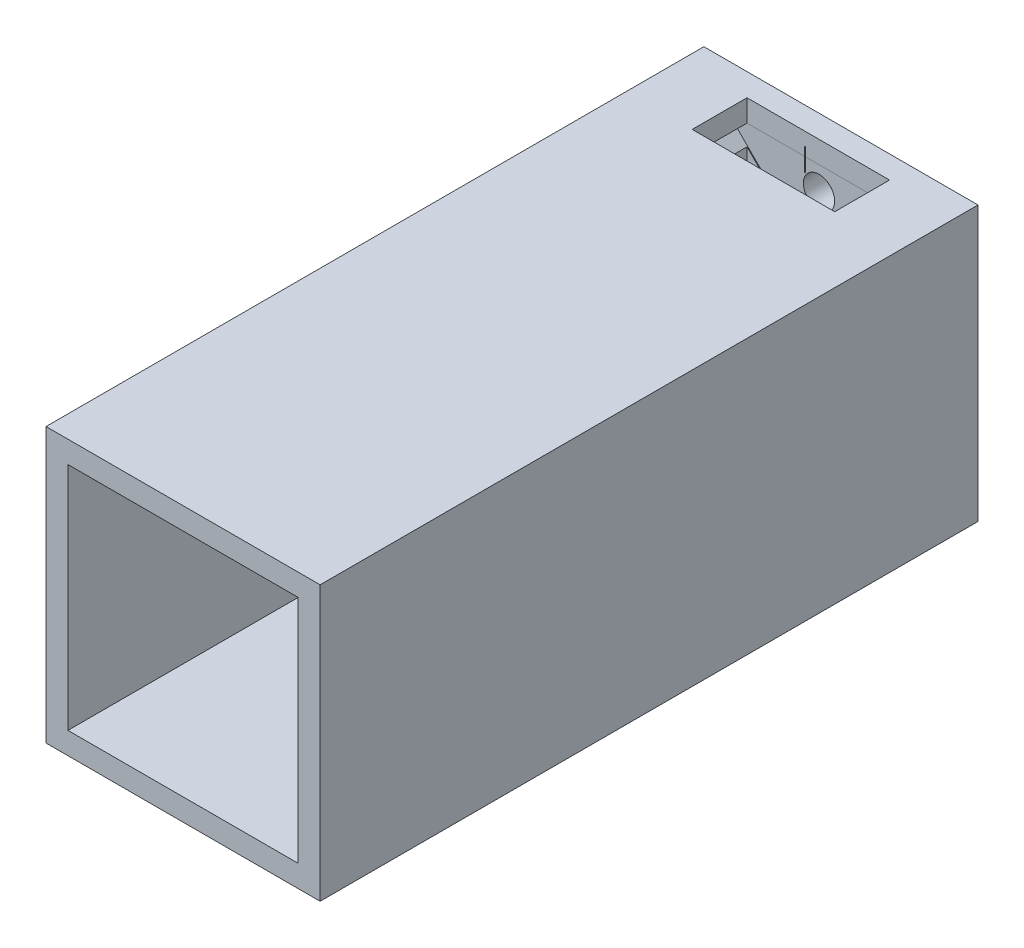
from build123d import *

# Parameters (mm, degrees)
SKETCH1_W           = 25
SKETCH1_H           = 25
BOSS_EXTRUDE1_DEPTH = 60
SHELL1_T            = -2
SKETCH2_R           = 2.5
SKETCH2_R_2         = 1.425
CUT_EXTRUDE4_DEPTH  = 2
BOSS_EXTRUDE3_DEPTH = 30
SKETCH5_W           = 13
SKETCH5_H           = 5
SKETCH5_R           = 0.024622166
CUT_EXTRUDE6_DEPTH  = 10


with BuildPart() as part:
    # Sketch1 → Boss-Extrude1 (new body)
    with BuildSketch(Plane.XY):
        Rectangle(SKETCH1_W, SKETCH1_H)
    extrude(amount=BOSS_EXTRUDE1_DEPTH)

    # Shell1
    shell1_openings = [part.faces().sort_by_distance(p)[0] for p in [
        (0, 0, 60),
    ]]
    offset(amount=SHELL1_T, openings=shell1_openings, kind=Kind.INTERSECTION)

    # Sketch2 → Cut-Extrude4 (cut)
    with BuildSketch(Plane.XY):
        Circle(SKETCH2_R)
        with Locations((8.25, 0)):
            Circle(SKETCH2_R_2)
        with Locations((0, -8.25)):
            Circle(SKETCH2_R_2)
        with Locations((-8.25, 0)):
            Circle(SKETCH2_R_2)
        with Locations((0, 8.25)):
            Circle(SKETCH2_R_2)
    extrude(amount=CUT_EXTRUDE4_DEPTH, mode=Mode.SUBTRACT)

    # Sketch4 → Boss-Extrude3 (add)
    with BuildSketch(Plane.XY.offset(2)):
        with BuildLine():
            Line((-8.871320344, 6.75), (-6.792832126, 4.671511782))
            ThreePointArc((-6.792832126, 4.671511782), (-6.28187766, 5.363494358), (-5.703280287, 6))
            Line((-5.703280287, 6), (-3.878679656, 6))
            Line((-3.878679656, 6), (-4.628679656, 6.75))
            Line((-4.628679656, 6.75), (-8.871320344, 6.75))
        make_face()
        Polygon((-10.5, 8.378679656), (-8.871320344, 6.75), (-4.628679656, 6.75), (-8.378679656, 10.5), (-10.5, 10.5), align=None)
        Polygon((-3.878679656, 6), (0, 6), (3.878679656, 6), (4.628679656, 6.75), (-4.628679656, 6.75), align=None)
        Polygon((8.378679656, 10.5), (4.628679656, 6.75), (8.871320344, 6.75), (10.5, 8.378679656), (10.5, 10.5), align=None)
        with BuildLine():
            Line((4.628679656, 6.75), (3.878679656, 6))
            Line((3.878679656, 6), (4.296719713, 6))
            ThreePointArc((4.296719713, 6), (5.489948643, 5.313054416), (6.513606116, 4.392285772))
            Line((6.513606116, 4.392285772), (8.871320344, 6.75))
            Line((8.871320344, 6.75), (4.628679656, 6.75))
        make_face()
        with BuildLine():
            ThreePointArc((-5.703280287, -6), (-6.28187766, -5.363494358), (-6.792832126, -4.671511782))
            Line((-6.792832126, -4.671511782), (-8.871320344, -6.75))
            Line((-8.871320344, -6.75), (-4.628679656, -6.75))
            Line((-4.628679656, -6.75), (-3.878679656, -6))
            Line((-3.878679656, -6), (-5.703280287, -6))
        make_face()
        with BuildLine():
            Line((4.296719713, -6), (3.878679656, -6))
            Line((3.878679656, -6), (4.628679656, -6.75))
            Line((4.628679656, -6.75), (8.871320344, -6.75))
            Line((8.871320344, -6.75), (6.513606116, -4.392285772))
            ThreePointArc((6.513606116, -4.392285772), (5.489948643, -5.313054416), (4.296719713, -6))
        make_face()
        Polygon((-4.628679656, -6.75), (-8.871320344, -6.75), (-10.5, -8.378679656), (-10.5, -10.5), (-8.378679656, -10.5), align=None)
        Polygon((8.871320344, -6.75), (4.628679656, -6.75), (8.378679656, -10.5), (10.5, -10.5), (10.5, -8.378679656), align=None)
        with BuildLine():
            Line((8.871320344, 6.75), (6.513606116, 4.392285772))
            ThreePointArc((6.513606116, 4.392285772), (7.473760778, 3.000900651), (8.046659593, 1.410417555))
            ThreePointArc((8.046659593, 1.410417555), (8.886964121, 1.274716325), (9.5, 0.684196609))
            Line((9.5, 0.684196609), (9.5, 6.75))
            Line((9.5, 6.75), (8.871320344, 6.75))
        make_face()
        with BuildLine():
            ThreePointArc((8.046659593, -1.410417555), (7.473760778, -3.000900651), (6.513606116, -4.392285772))
            Line((6.513606116, -4.392285772), (8.871320344, -6.75))
            Line((8.871320344, -6.75), (9.5, -6.75))
            Line((9.5, -6.75), (9.5, -0.684196609))
            ThreePointArc((9.5, -0.684196609), (8.886964121, -1.274716325), (8.046659593, -1.410417555))
        make_face()
        Polygon((3.878679656, -6), (0, -6), (-3.878679656, -6), (-4.628679656, -6.75), (4.628679656, -6.75), align=None)
        with BuildLine():
            ThreePointArc((-6.792832126, -4.671511782), (-7.607218745, -3.110608316), (-8.080808179, -1.414920184))
            ThreePointArc((-8.080808179, -1.414920184), (-8.902323398, -1.26692509), (-9.5, -0.684196609))
            Line((-9.5, -0.684196609), (-9.5, -6.75))
            Line((-9.5, -6.75), (-8.871320344, -6.75))
            Line((-8.871320344, -6.75), (-6.792832126, -4.671511782))
        make_face()
        with BuildLine():
            ThreePointArc((-9.5, 0.684196609), (-8.902323398, 1.26692509), (-8.080808179, 1.414920184))
            ThreePointArc((-8.080808179, 1.414920184), (-7.607218745, 3.110608316), (-6.792832126, 4.671511782))
            Line((-6.792832126, 4.671511782), (-8.871320344, 6.75))
            Line((-8.871320344, 6.75), (-9.5, 6.75))
            Line((-9.5, 6.75), (-9.5, 0.684196609))
        make_face()
        with BuildLine():
            ThreePointArc((-8.080808179, -1.414920184), (-8.170149368, -0.709965812), (-8.2, 0))
            ThreePointArc((-8.2, 0), (-8.170149368, 0.709965812), (-8.080808179, 1.414920184))
            ThreePointArc((-8.080808179, 1.414920184), (-8.902323398, 1.26692509), (-9.5, 0.684196609))
            Line((-9.5, 0.684196609), (-9.5, -0.684196609))
            ThreePointArc((-9.5, -0.684196609), (-8.902323398, -1.26692509), (-8.080808179, -1.414920184))
        make_face()
        with BuildLine():
            ThreePointArc((8.046659593, 1.410417555), (8.161552283, 0.709364321), (8.2, 0))
            ThreePointArc((8.2, 0), (8.161552283, -0.709364321), (8.046659593, -1.410417555))
            ThreePointArc((8.046659593, -1.410417555), (8.886964121, -1.274716325), (9.5, -0.684196609))
            Line((9.5, -0.684196609), (9.5, 0.684196609))
            ThreePointArc((9.5, 0.684196609), (8.886964121, 1.274716325), (8.046659593, 1.410417555))
        make_face()
    extrude(amount=BOSS_EXTRUDE3_DEPTH)

    # Sketch5 → Cut-Extrude6 (cut)
    with BuildSketch(Plane(origin=(0, 12.5, 0), x_dir=(1, 0, 0), z_dir=(0, 1, 0))):
        with Locations((0, -4.566766708)):
            Rectangle(SKETCH5_W, SKETCH5_H)
        with Locations((0.024622166, -3.301323142)):
            Circle(SKETCH5_R, mode=Mode.SUBTRACT)
    extrude(amount=-CUT_EXTRUDE6_DEPTH, mode=Mode.SUBTRACT)


solid = part.part
